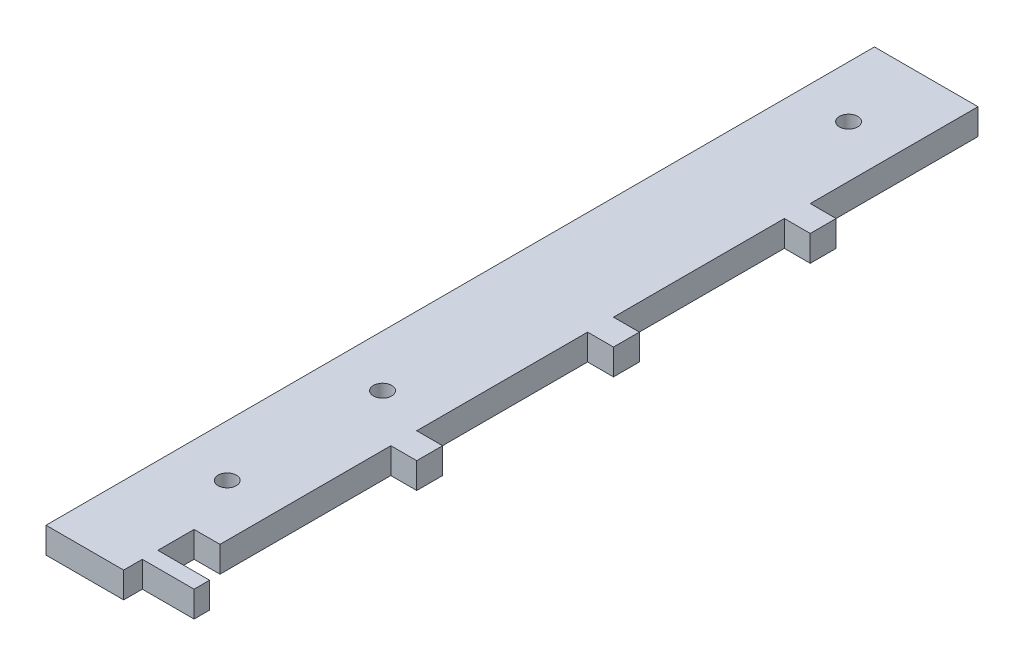
from build123d import *

# Parameters (mm, degrees)
SKETCH1_W                                           = 31.75
SKETCH1_H                                           = 203.2
BOSS_EXTRUDE1_DEPTH                                 = 6.35
SKETCH2_W                                           = 6.35
SKETCH2_H                                           = 41.148
SKETCH2_H_2                                         = 41.91
SKETCH2_W_2                                         = 12.7
SKETCH2_H_3                                         = 4.572
CUT_EXTRUDE1_DEPTH                                  = 7.35
CBORE_FOR_8_BINDING_HEAD_MACHINE_SCREW1_D           = 4.4958
CBORE_FOR_8_BINDING_HEAD_MACHINE_SCREW1_CBORE_D     = 9.525
CBORE_FOR_8_BINDING_HEAD_MACHINE_SCREW1_CBORE_DEPTH = 3.175


with BuildPart() as part:
    # Sketch1 → Boss-Extrude1 (new body)
    with BuildSketch(Plane(origin=(0, 0, 0), x_dir=(1, 0, 0), z_dir=(0, 1, 0))):
        with Locations((15.875, 101.6)):
            Rectangle(SKETCH1_W, SKETCH1_H)
    extrude(amount=BOSS_EXTRUDE1_DEPTH)

    # Sketch2 → Cut-Extrude1 (cut, through all)
    with BuildSketch(Plane(origin=(0, 6.35, 0), x_dir=(1, 0, 0), z_dir=(0, 1, 0))):
        with Locations((28.575, 182.626)):
            Rectangle(SKETCH2_W, SKETCH2_H)
        with Locations((28.575, 134.747)):
            Rectangle(SKETCH2_W, SKETCH2_H_2)
        Polygon((31.75, 59.182), (25.4, 59.182), (25.4, 17.272), (19.05, 17.272), (19.05, 8.382), (31.75, 8.382), align=None)
        with Locations((28.575, 86.487)):
            Rectangle(SKETCH2_W, SKETCH2_H_2)
        with Locations((25.4, 2.286)):
            Rectangle(SKETCH2_W_2, SKETCH2_H_3)
    extrude(amount=-CUT_EXTRUDE1_DEPTH, mode=Mode.SUBTRACT)

    # CBORE for #8 Binding Head Machine Screw1 (through all)
    with Locations(Plane(origin=(0, 0, 0), x_dir=(-1, 0, 0), z_dir=(0, -1, 0))):
        with Locations((-12.7, 31.75), (-12.7, 69.85), (-12.7, 184.15)):
            CounterBoreHole(CBORE_FOR_8_BINDING_HEAD_MACHINE_SCREW1_D / 2, CBORE_FOR_8_BINDING_HEAD_MACHINE_SCREW1_CBORE_D / 2, CBORE_FOR_8_BINDING_HEAD_MACHINE_SCREW1_CBORE_DEPTH)


solid = part.part
